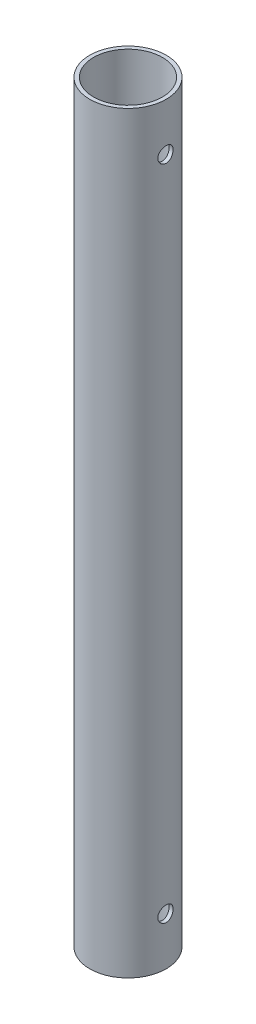
from build123d import *

# Parameters (mm, degrees)
SKETCH1_R           = 10
SKETCH1_R_2         = 9
BOSS_EXTRUDE1_DEPTH = 197
SKETCH2_R           = 2
CUT_EXTRUDE1_DEPTH  = 21


with BuildPart() as part:
    # Sketch1 → Boss-Extrude1 (new body)
    with BuildSketch(Plane(origin=(0, 0, 0), x_dir=(1, 0, 0), z_dir=(0, 1, 0))):
        Circle(SKETCH1_R)
        Circle(SKETCH1_R_2, mode=Mode.SUBTRACT)
    extrude(amount=BOSS_EXTRUDE1_DEPTH)

    # Sketch2 → Cut-Extrude1 (cut, through all)
    with BuildSketch(Plane(origin=(10, 0, 0), x_dir=(0, 0, -1), z_dir=(1, 0, 0))):
        with Locations((0, 184.5)):
            Circle(SKETCH2_R)
        with Locations((0, 12.5)):
            Circle(SKETCH2_R)
    extrude(amount=-CUT_EXTRUDE1_DEPTH, mode=Mode.SUBTRACT)


solid = part.part
